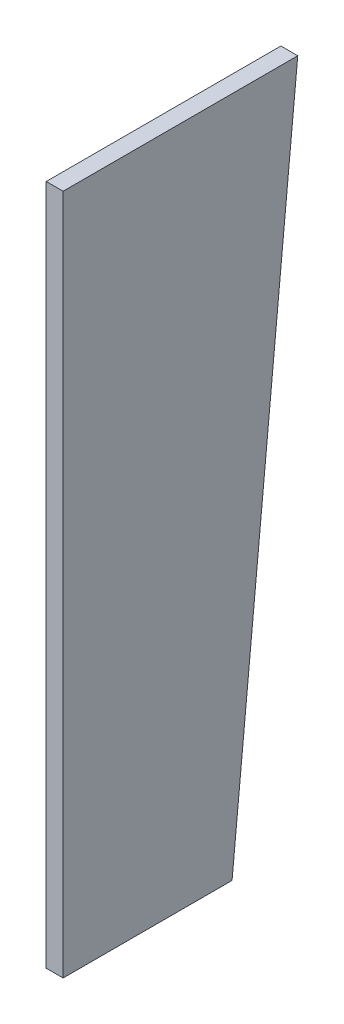
from build123d import *

# Parameters (mm, degrees)
BOSS_EXTRUDE1_DEPTH = 18


with BuildPart() as part:
    # Sketch1 → Boss-Extrude1 (new body)
    with BuildSketch(Plane(origin=(0, 0, 0), x_dir=(0, 0, -1), z_dir=(1, 0, 0))):
        Polygon((0, 0), (0, 726), (250, 726), (180, 0), align=None)
    extrude(amount=BOSS_EXTRUDE1_DEPTH)


solid = part.part
